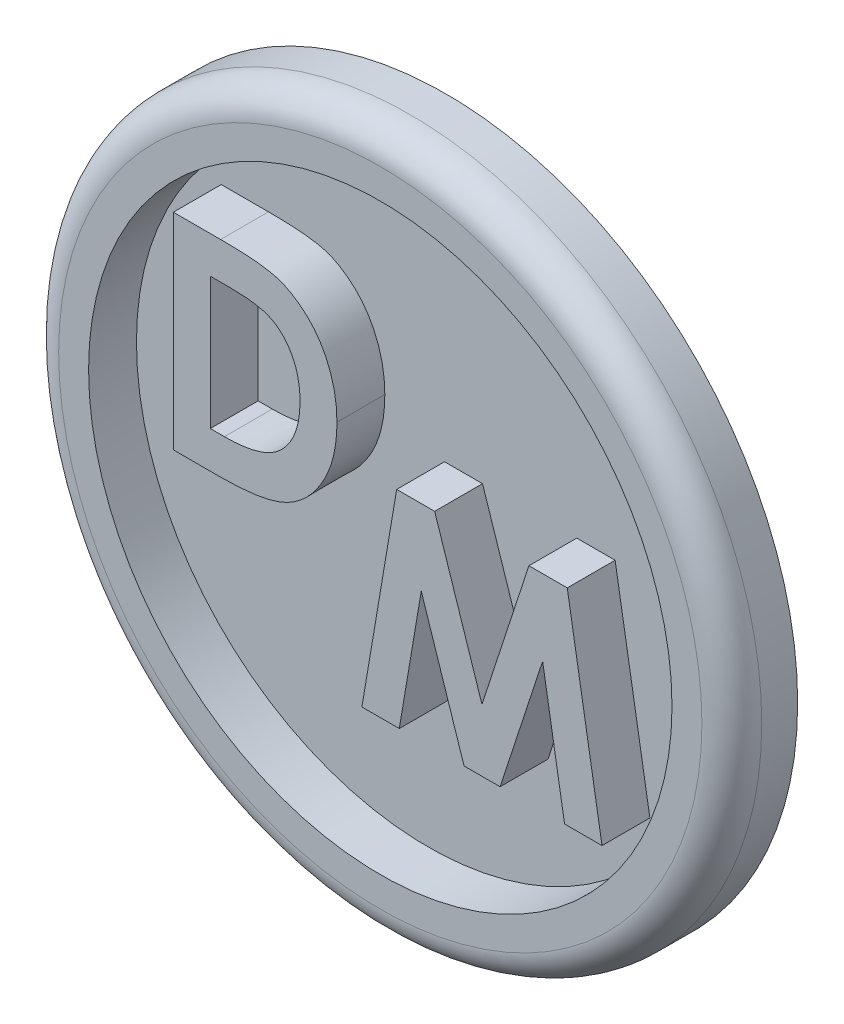
from build123d import *

# Parameters (mm, degrees)
SKETCH1_R           = 11.75
BOSS_EXTRUDE1_DEPTH = 0.6
SKETCH2_R           = 11.75
SKETCH2_R_2         = 9.75
BOSS_EXTRUDE2_DEPTH = 1.6
BOSS_EXTRUDE3_DEPTH = 1.6
FILLET1_R           = 1


with BuildPart() as part:
    # Sketch1 → Boss-Extrude1 (new body)
    with BuildSketch(Plane.XY):
        Circle(SKETCH1_R)
    extrude(amount=BOSS_EXTRUDE1_DEPTH)

    # Sketch2 → Boss-Extrude2 (add)
    with BuildSketch(Plane.XY.offset(0.6)):
        Circle(SKETCH2_R)
        Circle(SKETCH2_R_2, mode=Mode.SUBTRACT)
    extrude(amount=BOSS_EXTRUDE2_DEPTH)

    # Sketch3 → Boss-Extrude3 (add)
    with BuildSketch(Plane.XY.offset(0.6)):
        with BuildLine():
            Line((-6.916956338, -0.911963991), (-5.361151216, -0.911963991))
            add(Edge.make_bspline(
                [(-5.361151216, -0.911963991), (-5.239855358, -0.911135682), (-5.005389093, -0.909534551), (-4.665741882, -0.890804083), (-4.349677023, -0.863299234), (-4.057909505, -0.821204302), (-3.789388655, -0.772346551), (-3.546096572, -0.706915643), (-3.326053246, -0.631828045), (-3.126949332, -0.544340632), (-2.945683277, -0.44173815), (-2.7747857, -0.326468517), (-2.612283679, -0.196802417), (-2.45727666, -0.052438003), (-2.309386888, 0.10566485), (-2.172085953, 0.280689674), (-2.040972084, 0.468103096), (-1.918172617, 0.668555578), (-1.808865755, 0.881651378), (-1.711570392, 1.104036522), (-1.630505782, 1.335855545), (-1.564500099, 1.576788364), (-1.511922924, 1.826137054), (-1.475126432, 2.084376718), (-1.452380824, 2.351276025), (-1.4500733, 2.532166496), (-1.448900782, 2.624082016)],
                knots=[0, 0, 0, 0, 0.000363844, 0.000703314, 0.001020209, 0.001315264, 0.001587422, 0.001838456, 0.002070302, 0.002284378, 0.002489835, 0.002694315, 0.002902211, 0.00311283, 0.003329292, 0.003550963, 0.003779572, 0.004015201, 0.004255569, 0.004497496, 0.004742868, 0.004991603, 0.005246465, 0.005506831, 0.005773705, 0.006049398, 0.006049398, 0.006049398, 0.006049398], degree=3))
            add(Edge.make_bspline(
                [(-1.448900782, 2.624082016), (-1.451970756, 2.753780967), (-1.458014179, 3.009100945), (-1.508926104, 3.383777758), (-1.591254497, 3.742951732), (-1.707062559, 4.083771806), (-1.850470901, 4.403352066), (-2.022220096, 4.695290765), (-2.217376545, 4.960182986), (-2.437672033, 5.19363362), (-2.675821661, 5.395516124), (-2.924276522, 5.566399637), (-3.182814338, 5.703564799), (-3.41110213, 5.789220823), (-3.609613669, 5.843055986), (-3.783646836, 5.874330612), (-3.981711628, 5.903336547), (-4.204554541, 5.928267914), (-4.452836402, 5.945340974), (-4.725788377, 5.957131127), (-5.023476578, 5.965891962), (-5.23023053, 5.966754323), (-5.337724567, 5.967202676)],
                knots=[0, 0, 0, 0, 0.000388958, 0.000765687, 0.001132051, 0.001492876, 0.0018438, 0.002181059, 0.002507107, 0.002828814, 0.003141656, 0.003442084, 0.0037318, 0.004017439, 0.00417154, 0.004348294, 0.004547467, 0.004772083, 0.005020776, 0.005293909, 0.005591681, 0.005914153, 0.005914153, 0.005914153, 0.005914153], degree=3))
            Line((-5.337724567, 5.967202676), (-6.916956338, 5.967202676))
            Line((-6.916956338, 5.967202676), (-6.916956338, -0.911963991))
        make_face()
        with BuildLine():
            Line((-5.682234116, 0.322758231), (-5.682234116, 4.732480453))
            Line((-5.682234116, 4.732480453), (-5.037312241, 4.732480453))
            add(Edge.make_bspline(
                [(-5.037312241, 4.732480453), (-4.960589746, 4.732108932), (-4.813049194, 4.73139448), (-4.599773783, 4.721578003), (-4.402949586, 4.705637209), (-4.222318791, 4.682058374), (-4.05746614, 4.653687), (-3.90899297, 4.61859535), (-3.776606644, 4.575921232), (-3.659215448, 4.525629351), (-3.552039877, 4.468210013), (-3.452750381, 4.401161931), (-3.356923903, 4.32665025), (-3.266331588, 4.24255096), (-3.180635874, 4.149959395), (-3.100343516, 4.048403256), (-3.024378224, 3.938192199), (-2.954709427, 3.818739134), (-2.890985622, 3.691323934), (-2.834687293, 3.557108901), (-2.787161197, 3.415362356), (-2.751069756, 3.266147042), (-2.720324605, 3.110388904), (-2.698124248, 2.947086468), (-2.686029416, 2.77677325), (-2.684432963, 2.66084794), (-2.683623005, 2.602033405)],
                knots=[0, 0, 0, 0, 0.000230149, 0.000442586, 0.000640338, 0.000822375, 0.000988895, 0.001141975, 0.001279683, 0.00140562, 0.001524619, 0.001643866, 0.001764607, 0.001888454, 0.002014249, 0.002142732, 0.002276515, 0.002415486, 0.002557229, 0.00270362, 0.002851783, 0.003005191, 0.003163833, 0.00332793, 0.003499256, 0.003675693, 0.003675693, 0.003675693, 0.003675693], degree=3))
            add(Edge.make_bspline(
                [(-2.683623005, 2.602033405), (-2.685262463, 2.511908699), (-2.688459279, 2.336172506), (-2.719481404, 2.080243078), (-2.769467097, 1.839548826), (-2.842282437, 1.614708069), (-2.931826264, 1.404291395), (-3.045683112, 1.211010286), (-3.176936165, 1.031696657), (-3.280787507, 0.926524812), (-3.332678994, 0.873973509)],
                knots=[0, 0, 0, 0, 0.000270268, 0.000527001, 0.000772141, 0.001006602, 0.001234957, 0.001456654, 0.001678245, 0.001899543, 0.001899543, 0.001899543, 0.001899543], degree=3))
            add(Edge.make_bspline(
                [(-3.332678994, 0.873973509), (-3.383844652, 0.829191175), (-3.488344714, 0.737728328), (-3.671812484, 0.628132448), (-3.873984463, 0.531841725), (-4.099485742, 0.455493921), (-4.346136951, 0.395114822), (-4.615407148, 0.353472834), (-4.905854335, 0.326714134), (-5.107069378, 0.324105116), (-5.210945053, 0.322758231)],
                knots=[0, 0, 0, 0, 0.000203614, 0.000415859, 0.00063839, 0.000874594, 0.001128605, 0.001399336, 0.001691279, 0.002002825, 0.002002825, 0.002002825, 0.002002825], degree=3))
            Line((-5.210945053, 0.322758231), (-5.682234116, 0.322758231))
        make_face(mode=Mode.SUBTRACT)
        Polygon((6.248715571, 1.676089617), (4.96714005, 1.676089617), (3.397554546, -3.122239376), (1.816944737, 1.676089617), (0.54777156, 1.676089617), (-0.615292676, -5.20307705), (0.634587966, -5.20307705), (1.369082324, -0.858122623), (2.79948597, -5.20307705), (4.003891352, -5.20307705), (5.426026769, -0.858122623), (6.159143088, -5.20307705), (7.410401769, -5.20307705), align=None)
    extrude(amount=BOSS_EXTRUDE3_DEPTH)

    # Fillet1
    fillet1_edges = [part.edges().sort_by_distance(p)[0] for p in [
        (-11.75, 0, 2.2),
    ]]
    fillet(fillet1_edges, radius=FILLET1_R)


solid = part.part
